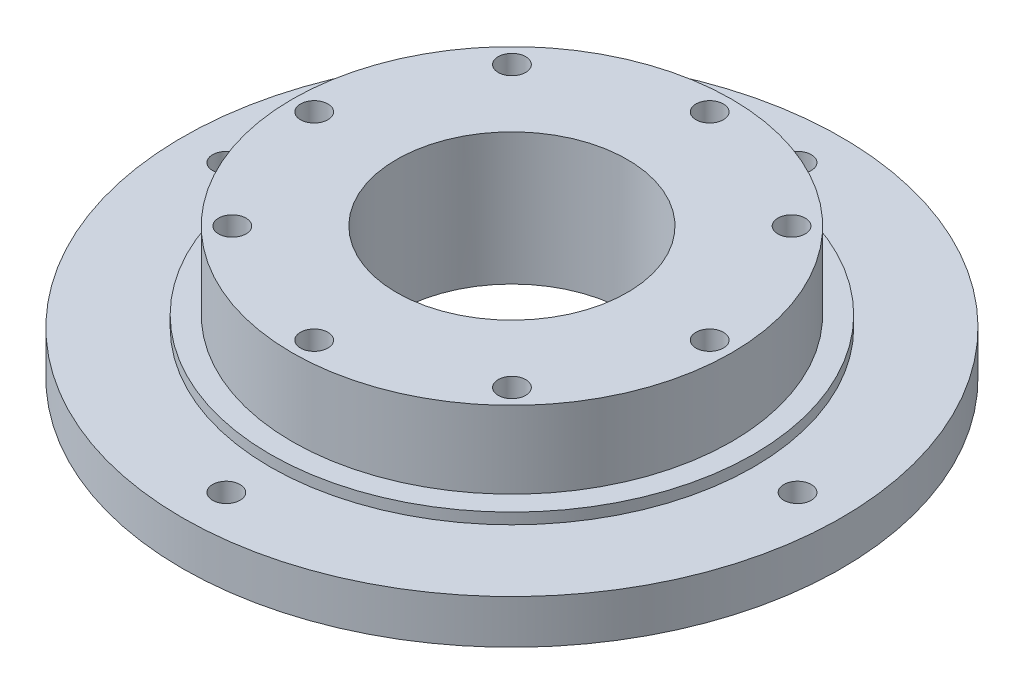
from build123d import *

# Parameters (mm, degrees)
SKETCH1_R             = 30
BASE_CORE_DEPTH       = 4
SKETCH2_R             = 22
CLEARNESS_DEPTH       = 1
SKETCH3_R             = 20
BREAING_40_ID_DEPTH   = 7
SKETCH4_R             = 10.5
BREAING_21_OD_DEPTH   = 5
SKETCH5_R             = 10.5
MOTOR_CUT_DEPTH       = 7
M3_TAPPED_HOLE2_D     = 2.5
M3_TAPPED_HOLE2_DEPTH = 6.748924226
M3_TAPPED_HOLE2_TIP   = 0.751075774
M3_TAPPED_HOLE1_D     = 2.5


with BuildPart() as part:
    # Sketch1 → base-core (new body)
    with BuildSketch(Plane(origin=(0, 0, 0), x_dir=(1, 0, 0), z_dir=(0, 1, 0))):
        Circle(SKETCH1_R)
    extrude(amount=-BASE_CORE_DEPTH)

    # Sketch2 → clearness (add)
    with BuildSketch(Plane(origin=(0, 0, 0), x_dir=(1, 0, 0), z_dir=(0, 1, 0))):
        Circle(SKETCH2_R)
    extrude(amount=CLEARNESS_DEPTH)

    # Sketch3 → breaing-40-ID (add)
    with BuildSketch(Plane(origin=(0, 1, 0), x_dir=(1, 0, 0), z_dir=(0, 1, 0))):
        Circle(SKETCH3_R)
    extrude(amount=BREAING_40_ID_DEPTH)

    # Sketch4 → breaing-21-OD (cut)
    with BuildSketch(Plane(origin=(0, 8, 0), x_dir=(1, 0, 0), z_dir=(0, 1, 0))):
        Circle(SKETCH4_R)
    extrude(amount=-BREAING_21_OD_DEPTH, mode=Mode.SUBTRACT)

    # Sketch5 → motor-cut (cut)
    with BuildSketch(Plane.XZ.offset(4)):
        Circle(SKETCH5_R)
    extrude(amount=-MOTOR_CUT_DEPTH, mode=Mode.SUBTRACT)

    # M3 Tapped Hole2
    with Locations(Plane(origin=(0, 8, 0), x_dir=(1, 0, 0), z_dir=(0, 1, 0))):
        with Locations((12.727922061, 12.727922061), (18, 0), (12.727922061, -12.727922061), (0, -18), (-12.727922061, -12.727922061), (-18, 0), (-12.727922061, 12.727922061), (0, 18), (0, 0)):
            Hole(M3_TAPPED_HOLE2_D / 2, depth=M3_TAPPED_HOLE2_DEPTH)
            with Locations((0, 0, -(M3_TAPPED_HOLE2_DEPTH + M3_TAPPED_HOLE2_TIP / 2))):  # 118° drill point
                Cone(0, M3_TAPPED_HOLE2_D / 2, M3_TAPPED_HOLE2_TIP, mode=Mode.SUBTRACT)

    # M3 Tapped Hole1 (through all)
    with Locations(Plane.XZ.offset(4)):
        with Locations((-26, 0), (0, 26), (26, 0), (0, -26)):
            Hole(M3_TAPPED_HOLE1_D / 2)


solid = part.part
